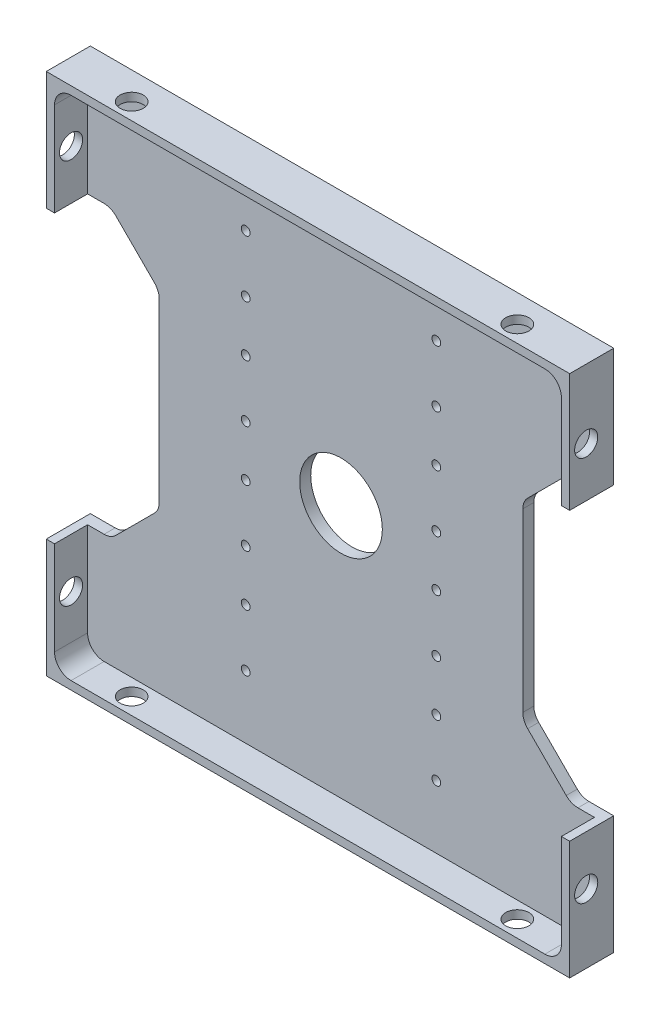
from build123d import *

# Parameters (mm, degrees)
SKETCH1_W                       = 96
SKETCH1_H                       = 96
BOSS_EXTRUDE1_DEPTH             = 8
SKETCH2_W                       = 92
SKETCH2_H                       = 92
COMPONENT_PLATFORM_DEPTH        = 6
CABLE_SLOTS_DEPTH               = 6
SKETCH4_R                       = 7.5
CENTER_MASS_CUT_DEPTH           = 6
INNER_CORNER_FILLETS_R          = 3
TAP_DRILL_FOR_M5X0_8_TAP2_D     = 4.2
TAP_DRILL_FOR_M5X0_8_TAP2_DEPTH = 2
TAP_DRILL_FOR_M2X0_4_TAP2_D     = 1.6
TAP_DRILL_FOR_M5X0_8_TAP1_D     = 4.2
TAP_DRILL_FOR_M5X0_8_TAP1_DEPTH = 2
CUT_EXTRUDE1_START              = -8
SKETCH28_OUTSIDE_W              = 125.2
SKETCH28_OUTSIDE_H              = 125.2
SKETCH28_OUTSIDE_W_2            = 95
SKETCH28_OUTSIDE_H_2            = 95
CUT_EXTRUDE1_DEPTH              = 8


with BuildPart() as part:
    # Sketch1 → Boss-Extrude1 (new body)
    with BuildSketch(Plane.XY):
        Rectangle(SKETCH1_W, SKETCH1_H)
    extrude(amount=BOSS_EXTRUDE1_DEPTH)

    # Sketch2 → Component Platform (cut)
    with BuildSketch(Plane.XY.offset(8)):
        Rectangle(SKETCH2_W, SKETCH2_H)
    extrude(amount=-COMPONENT_PLATFORM_DEPTH, mode=Mode.SUBTRACT)

    # Sketch3 → Cable Slots (cut, symmetric)
    with BuildSketch(Plane.XY.offset(2)):
        with BuildLine():
            Line((-40.878679656, -25.121320344), (-33.878679656, -18.121320344))
            ThreePointArc((-33.878679656, -18.121320344), (-33.228361402, -17.148050297), (-33, -16))
            Line((-33, -16), (-33, 16))
            ThreePointArc((-33, 16), (-33.228361402, 17.148050297), (-33.878679656, 18.121320344))
            Line((-33.878679656, 18.121320344), (-40.878679656, 25.121320344))
            ThreePointArc((-40.878679656, 25.121320344), (-41.851949703, 25.771638598), (-43, 26))
            Line((-43, 26), (-48, 26))
            Line((-48, 26), (-48, -26))
            Line((-48, -26), (-43, -26))
            ThreePointArc((-43, -26), (-41.851949703, -25.771638598), (-40.878679656, -25.121320344))
        make_face()
        with BuildLine():
            Line((48, -26), (48, 26))
            Line((48, 26), (43, 26))
            ThreePointArc((43, 26), (41.851949703, 25.771638598), (40.878679656, 25.121320344))
            Line((40.878679656, 25.121320344), (33.878679656, 18.121320344))
            ThreePointArc((33.878679656, 18.121320344), (33.228361402, 17.148050297), (33, 16))
            Line((33, 16), (33, -16))
            ThreePointArc((33, -16), (33.228361402, -17.148050297), (33.878679656, -18.121320344))
            Line((33.878679656, -18.121320344), (40.878679656, -25.121320344))
            ThreePointArc((40.878679656, -25.121320344), (41.851949703, -25.771638598), (43, -26))
            Line((43, -26), (48, -26))
        make_face()
    extrude(amount=CABLE_SLOTS_DEPTH, both=True, mode=Mode.SUBTRACT)

    # Sketch4 → Center Mass Cut (cut)
    with BuildSketch(Plane.XY.offset(2)):
        Circle(SKETCH4_R)
    extrude(amount=-CENTER_MASS_CUT_DEPTH, mode=Mode.SUBTRACT)

    # Inner Corner Fillets
    inner_corner_fillets_edges = [part.edges().sort_by_distance(p)[0] for p in [
        (-46, -46, 5),
        (-46, 46, 5),
        (46, 46, 5),
        (46, -46, 5),
    ]]
    fillet(inner_corner_fillets_edges, radius=INNER_CORNER_FILLETS_R)

    # Tap Drill for M5x0.8 Tap2
    with Locations(Plane(origin=(0, -48, 0), x_dir=(-1, 0, 0), z_dir=(0, -1, 0))):
        with Locations((35, -5), (-35, -5)):
            tap_drill_for_m5x0_8_tap2 = Hole(TAP_DRILL_FOR_M5X0_8_TAP2_D / 2, depth=TAP_DRILL_FOR_M5X0_8_TAP2_DEPTH)

    # Mirror2: Tap Drill for M5x0.8 Tap2 across plane
    add(tap_drill_for_m5x0_8_tap2.mirror(Plane(origin=(0, 0, 0), x_dir=(0, 0, 1), z_dir=(0, -1, 0))), mode=Mode.SUBTRACT)

    # Tap Drill for M2x0.4 Tap2 (through all)
    with Locations(Plane.XY.offset(2)):
        with Locations((-17.3, 34.575), (-17.3, 24.225), (-17.3, 14.975), (-17.3, 4.625), (17.3, 4.625), (17.3, 14.975), (17.3, 24.225), (17.3, 34.575), (17.3, -4.625), (17.3, -14.975), (17.3, -24.225), (17.3, -34.575), (-17.3, -4.625), (-17.3, -14.975), (-17.3, -24.225), (-17.3, -34.575)):
            Hole(TAP_DRILL_FOR_M2X0_4_TAP2_D / 2)

    # Tap Drill for M5x0.8 Tap1
    with Locations(Plane(origin=(48, 0, 0), x_dir=(0, 0, -1), z_dir=(1, 0, 0))):
        with Locations((-5, -35), (-5, 35)):
            tap_drill_for_m5x0_8_tap1 = Hole(TAP_DRILL_FOR_M5X0_8_TAP1_D / 2, depth=TAP_DRILL_FOR_M5X0_8_TAP1_DEPTH)

    # Mirror3: Tap Drill for M5x0.8 Tap1 across plane
    add(tap_drill_for_m5x0_8_tap1.mirror(Plane(origin=(0, 0, 0), x_dir=(0, 0, 1), z_dir=(1, 0, 0))), mode=Mode.SUBTRACT)

    # Sketch28 outside → Cut-Extrude1 (cut)
    with BuildSketch(Plane(origin=(0, 0, 0), x_dir=(-1, 0, 0), z_dir=(0, 0, -1)).offset(CUT_EXTRUDE1_START)):
        Rectangle(SKETCH28_OUTSIDE_W, SKETCH28_OUTSIDE_H)
        Rectangle(SKETCH28_OUTSIDE_W_2, SKETCH28_OUTSIDE_H_2, mode=Mode.SUBTRACT)
    extrude(amount=CUT_EXTRUDE1_DEPTH, mode=Mode.SUBTRACT)


solid = part.part
